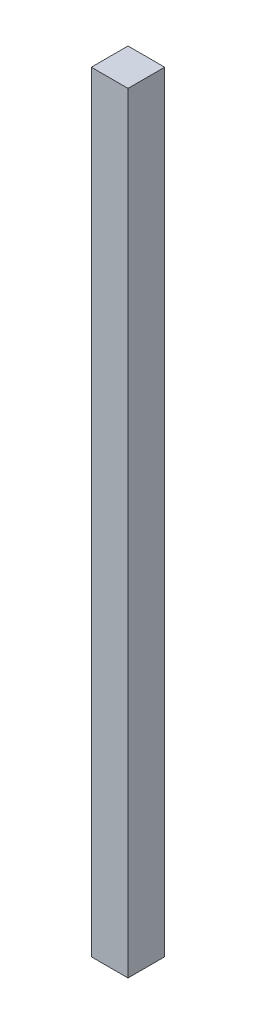
from build123d import *

# Parameters (mm, degrees)
SKETCH1_W           = 20
SKETCH1_H           = 20
BOSS_EXTRUDE1_DEPTH = 420


with BuildPart() as part:
    # Sketch1 → Boss-Extrude1 (new body)
    with BuildSketch(Plane(origin=(0, 0, 0), x_dir=(1, 0, 0), z_dir=(0, 1, 0))):
        with Locations((10, -10)):
            Rectangle(SKETCH1_W, SKETCH1_H)
    extrude(amount=BOSS_EXTRUDE1_DEPTH)


solid = part.part
